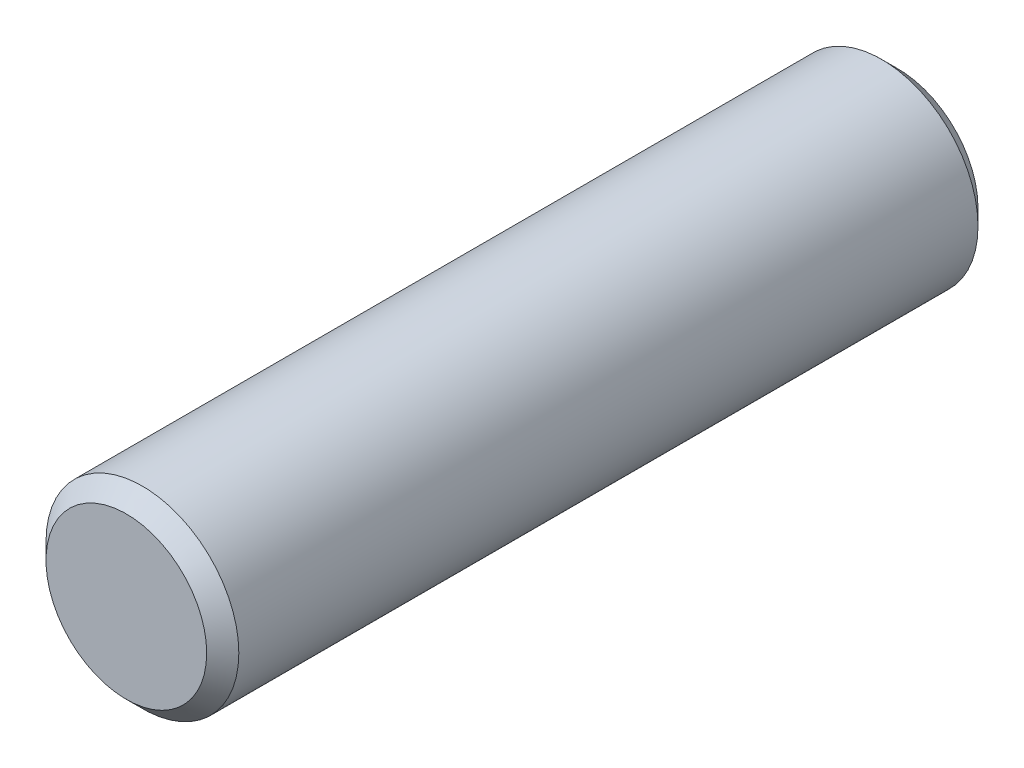
from build123d import *

# Parameters (mm, degrees)
ESQUISSE1_R          = 3
BASE_EXTRUSION_DEPTH = 24
CHANFREIN1_SIZE      = 0.5


with BuildPart() as part:
    # Esquisse1 → Base-Extrusion (new body)
    with BuildSketch(Plane.XY):
        Circle(ESQUISSE1_R)
    extrude(amount=BASE_EXTRUSION_DEPTH)

    # Chanfrein1
    chanfrein1_edges = [part.edges().sort_by_distance(p)[0] for p in [
        (-3, 0, 0),
        (-3, 0, 24),
    ]]
    chamfer(chanfrein1_edges, length=CHANFREIN1_SIZE)


solid = part.part
